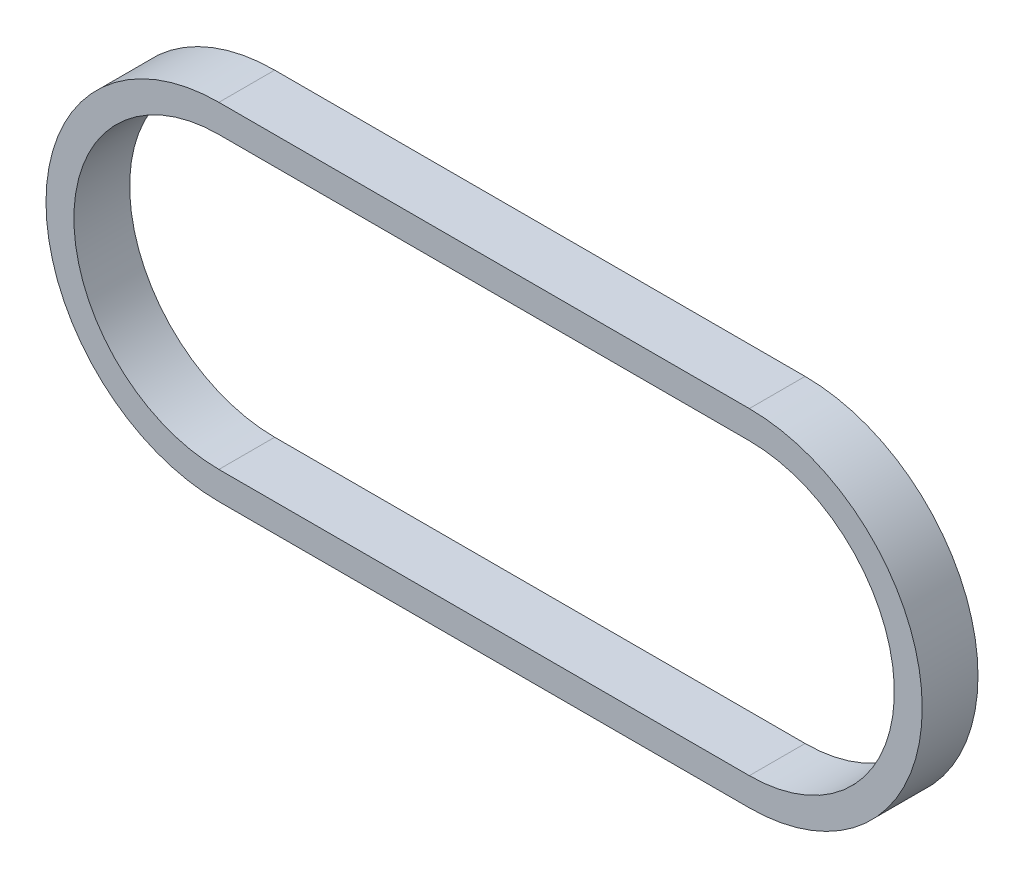
from build123d import *

# Parameters (mm, degrees)
BOSS_EXTRUDE1_DEPTH = 10


with BuildPart() as part:
    # Sketch1 → Boss-Extrude1 (new body)
    with BuildSketch(Plane.XY):
        with BuildLine():
            Line((0, 31), (95.1, 31))
            ThreePointArc((95.1, 31), (126.1, 0), (95.1, -31))
            Line((95.1, -31), (0, -31))
            ThreePointArc((0, -31), (-31, 0), (0, 31))
        make_face()
        with BuildLine():
            Line((0, 26), (95.1, 26))
            ThreePointArc((95.1, 26), (121.1, 0), (95.1, -26))
            Line((95.1, -26), (0, -26))
            ThreePointArc((0, -26), (-26, 0), (0, 26))
        make_face(mode=Mode.SUBTRACT)
    extrude(amount=BOSS_EXTRUDE1_DEPTH)


solid = part.part
